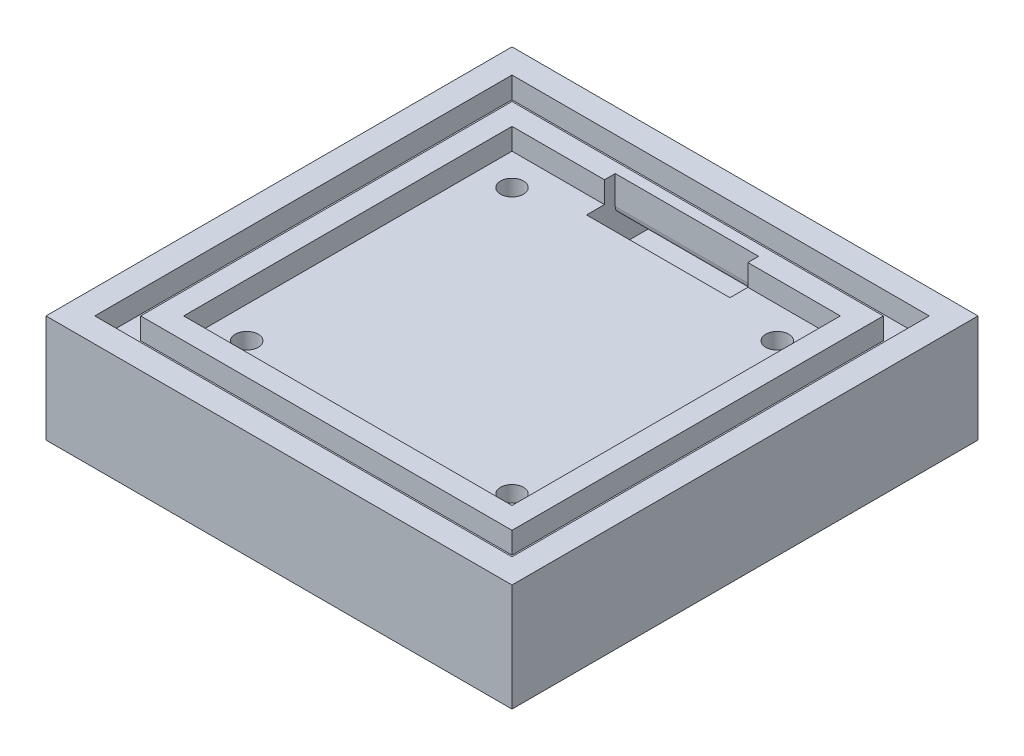
from build123d import *

# Parameters (mm, degrees)
SKETCH_1_W           = 65
SKETCH_1_H           = 65
EXTRUDE_1_DEPTH      = 15
SKETCH_2_R           = 1.6
CUT_EXTRUDE_1_DEPTH  = 16
SKETCH_3_W           = 45.8
SKETCH_3_H           = 45.8
CUT_EXTRUDE_2_DEPTH  = 3
SKETCH_4_W           = 58.2
SKETCH_4_H           = 58.2
SKETCH_4_W_2         = 51.8
SKETCH_4_H_2         = 51.8
CUT_EXTRUDE_3_DEPTH  = 3
SKETCH_7_R           = 3
CUT_EXTRUDE_6_DEPTH  = 5
SKETCH_10_W          = 20
SKETCH_10_H          = 4
CUT_EXTRUDE_9_DEPTH  = 9
SKETCH_11_W          = 20
SKETCH_11_H          = 4
CUT_EXTRUDE_10_DEPTH = 9
FILLET_2_R           = 4
FILLET_3_R           = 1


with BuildPart() as part:
    # 草图1 → 凸台-拉伸1 (new body)
    with BuildSketch(Plane(origin=(0, 0, 0), x_dir=(1, 0, 0), z_dir=(0, 1, 0))):
        with Locations((32.5, -32.5)):
            Rectangle(SKETCH_1_W, SKETCH_1_H)
    extrude(amount=EXTRUDE_1_DEPTH)

    # 草图2 → 切除-拉伸1 (cut, through all)
    with BuildSketch(Plane(origin=(0, 0, 0), x_dir=(-1, 0, 0), z_dir=(0, -1, 0))):
        with Locations((-14, -51)):
            Circle(SKETCH_2_R)
        with Locations((-51, -51)):
            Circle(SKETCH_2_R)
        with Locations((-14, -14)):
            Circle(SKETCH_2_R)
        with Locations((-51, -14)):
            Circle(SKETCH_2_R)
    extrude(amount=-CUT_EXTRUDE_1_DEPTH, mode=Mode.SUBTRACT)

    # 草图3 → 切除-拉伸2 (cut)
    with BuildSketch(Plane(origin=(0, 15, 0), x_dir=(1, 0, 0), z_dir=(0, 1, 0))):
        with Locations((32.5, -32.5)):
            Rectangle(SKETCH_3_W, SKETCH_3_H)
    extrude(amount=-CUT_EXTRUDE_2_DEPTH, mode=Mode.SUBTRACT)

    # 草图4 → 切除-拉伸3 (cut)
    with BuildSketch(Plane(origin=(0, 15, 0), x_dir=(1, 0, 0), z_dir=(0, 1, 0))):
        with Locations((32.5, -32.5)):
            Rectangle(SKETCH_4_W, SKETCH_4_H)
        with Locations((32.5, -32.5)):
            Rectangle(SKETCH_4_W_2, SKETCH_4_H_2, mode=Mode.SUBTRACT)
    extrude(amount=-CUT_EXTRUDE_3_DEPTH, mode=Mode.SUBTRACT)

    # 草图7 → 切除-拉伸6 (cut)
    with BuildSketch(Plane(origin=(0, 0, 0), x_dir=(-1, 0, 0), z_dir=(0, -1, 0))):
        with Locations((-14, -14)):
            Circle(SKETCH_7_R)
        with Locations((-14, -51)):
            Circle(SKETCH_7_R)
        with Locations((-51, -14)):
            Circle(SKETCH_7_R)
        with Locations((-51, -51)):
            Circle(SKETCH_7_R)
    extrude(amount=-CUT_EXTRUDE_6_DEPTH, mode=Mode.SUBTRACT)

    # 草图10 → 切除-拉伸9 (cut)
    with BuildSketch(Plane(origin=(0, 15, 0), x_dir=(1, 0, 0), z_dir=(0, 1, 0))):
        with Locations((32.5, -10.1)):
            Rectangle(SKETCH_10_W, SKETCH_10_H)
    extrude(amount=-CUT_EXTRUDE_9_DEPTH, mode=Mode.SUBTRACT)

    # 草图11 → 切除-拉伸10 (cut)
    with BuildSketch(Plane(origin=(0, 0, 0), x_dir=(-1, 0, 0), z_dir=(0, 0, -1))):
        with Locations((-32.5, 8)):
            Rectangle(SKETCH_11_W, SKETCH_11_H)
    extrude(amount=-CUT_EXTRUDE_10_DEPTH, mode=Mode.SUBTRACT)

    # 圆角2
    fillet_2_edges = [part.edges().sort_by_distance(p)[0] for p in [
        (32.5, 6, 12.1),
    ]]
    fillet(fillet_2_edges, radius=FILLET_2_R)

    # 圆角3
    fillet_3_edges = [part.edges().sort_by_distance(p)[0] for p in [
        (32.5, 10, 8.1),
    ]]
    fillet(fillet_3_edges, radius=FILLET_3_R)


solid = part.part
